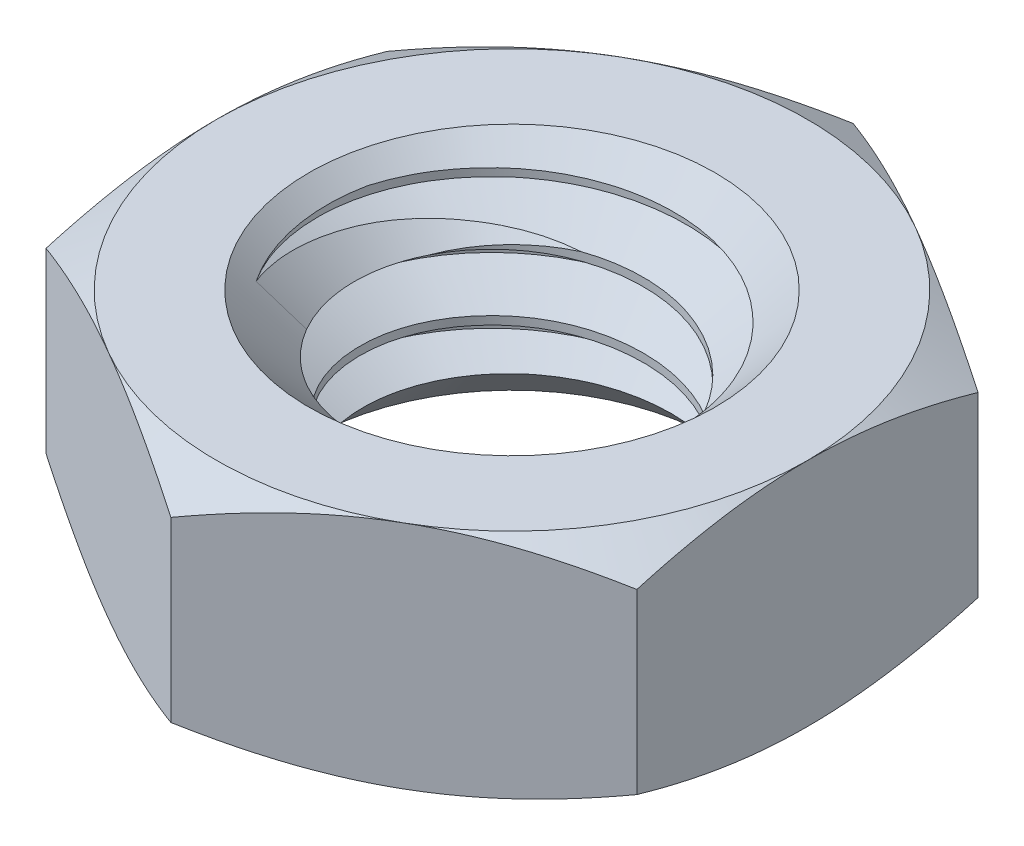
from build123d import *

# Parameters (mm, degrees)
SKETCH2_R                = 3.96875
BOSS_EXTRUDE1_DEPTH      = 2.4765
BOSS_EXTRUDE1_DEPTH_BACK = 2.4765
SKETCH4_R                = 3.96875
BOSS_EXTRUDE2_DEPTH      = 4.953
CUT_SWEEP1_PITCH         = 1.411111111
CUT_SWEEP1_HEIGHT        = 6.364111111
CUT_SWEEP1_RADIUS        = 3.96875
CUT_SWEEP1_START_ANGLE   = 180
SKETCH8_R                = 4.365625
BOSS_EXTRUDE3_DEPTH      = 4.953


with BuildPart() as part:
    # Sketch2 → Boss-Extrude1 (new, two sides)
    with BuildSketch(Plane(origin=(0, 0, 0), x_dir=(1, 0, 0), z_dir=(0, 1, 0))) as boss_extrude1_sk:
        Polygon((0, 7.332348419), (-6.35, 3.666174209), (-6.35, -3.666174209), (0, -7.332348419), (6.35, -3.666174209), (6.35, 3.666174209), align=None)
        with Locations(Location((0, 0, 0), (0, 0, 270))):
            Circle(SKETCH2_R, mode=Mode.SUBTRACT)
    extrude(amount=BOSS_EXTRUDE1_DEPTH)
    extrude(boss_extrude1_sk.sketch, amount=-BOSS_EXTRUDE1_DEPTH_BACK)

    # Sketch3 → Cut-Revolve1 (revolve, cut)
    with BuildSketch(Plane(origin=(0, 0, 0), x_dir=(0, 0, -1), z_dir=(1, 0, 0))):
        Polygon((-7.332348419, 1.909340876), (-6.35, 2.4765), (-7.332348419, 2.4765), align=None)
        Polygon((-7.332348419, -1.909340876), (-6.35, -2.4765), (-7.332348419, -2.4765), align=None)
        Polygon((-4.365625, 2.4765), (-3.96875, 2.4765), (-3.96875, 2.079625), align=None)
        Polygon((-4.365625, -2.4765), (-3.96875, -2.4765), (-3.96875, -2.079625), align=None)
    revolve(axis=Axis((0, 2.4765, 0), (0, -1, 0)), mode=Mode.SUBTRACT)

    # Sketch8 → Boss-Extrude3 (add)
    with BuildSketch(Plane(origin=(0, 2.4765, 0), x_dir=(1, 0, 0), z_dir=(0, 1, 0))):
        Circle(SKETCH8_R)
    extrude(amount=-BOSS_EXTRUDE3_DEPTH)


with BuildPart() as body_2:
    # Sketch4 → Boss-Extrude2 (new body)
    with BuildSketch(Plane(origin=(0, 2.4765, 0), x_dir=(1, 0, 0), z_dir=(0, 1, 0))):
        with Locations(Location((0, 0, 0), (0, 0, 270))):
            Circle(SKETCH4_R)
    extrude(amount=-BOSS_EXTRUDE2_DEPTH)

    # Cut-Sweep1: sweep along a helix
    with BuildLine() as cut_sweep1_path:
        add(Helix(CUT_SWEEP1_PITCH, CUT_SWEEP1_HEIGHT, CUT_SWEEP1_RADIUS, center=(0, 2.4765, 0), direction=(0, -1, 0), mode=Mode.PRIVATE).rotate(Axis((0, 2.4765, 0), (0, -1, 0)), CUT_SWEEP1_START_ANGLE))
    # Sketch6 → Cut-Sweep1 (sweep, cut)
    with BuildSketch(Plane(origin=(0, 0, 0), x_dir=(0, 0, -1), z_dir=(1, 0, 0))):
        Polygon((-4.045128629, 2.432402778), (-4.045128629, 3.755319444), (-3.052206448, 3.182055556), (-3.052206448, 3.005666667), align=None)
    sweep(path=cut_sweep1_path.line, is_frenet=True, mode=Mode.SUBTRACT)

    # Sketch7 → Revolve1 (revolve)
    with BuildSketch(Plane(origin=(0, 0, 0), x_dir=(0, 0, -1), z_dir=(1, 0, 0)), mode=Mode.PRIVATE) as revolve1_sk:
        Polygon((-4.365625, 2.4765), (-2.38125, 0.492125), (0, 0.492125), (0, 2.4765), align=None)
        Polygon((-4.365625, -2.4765), (0, -2.4765), (0, -0.492125), (-2.38125, -0.492125), align=None)
    revolve(revolve1_sk.sketch.rotate(Axis((0, -2.4765, 0), (0, 1, 0)), 303.531095579), axis=Axis((0, -2.4765, 0), (0, 1, 0)))


with BuildPart() as part_1:
    add(part.part)

    # Combine1: cut body 2
    add(body_2.part, mode=Mode.SUBTRACT)


solid = part_1.part
